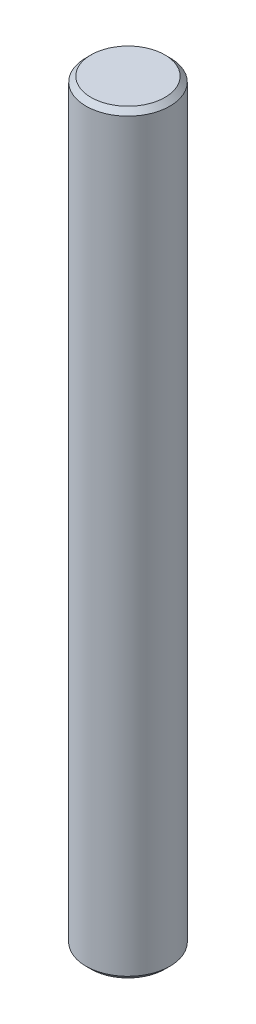
from build123d import *

# Parameters (mm, degrees)
SKETCH_1_R      = 2.5
EXTRUDE_1_DEPTH = 45
CHAMFER_1_SIZE  = 0.3


with BuildPart() as part:
    # Эскиз1 → Бобышка-Вытянуть1 (new body)
    with BuildSketch(Plane(origin=(0, 0, 0), x_dir=(1, 0, 0), z_dir=(0, 1, 0))):
        Circle(SKETCH_1_R)
    extrude(amount=EXTRUDE_1_DEPTH)

    # Фаска1
    chamfer_1_edges = [part.edges().sort_by_distance(p)[0] for p in [
        (-2.5, 0, 0),
        (-2.5, 45, 0),
    ]]
    chamfer(chamfer_1_edges, length=CHAMFER_1_SIZE)


solid = part.part
